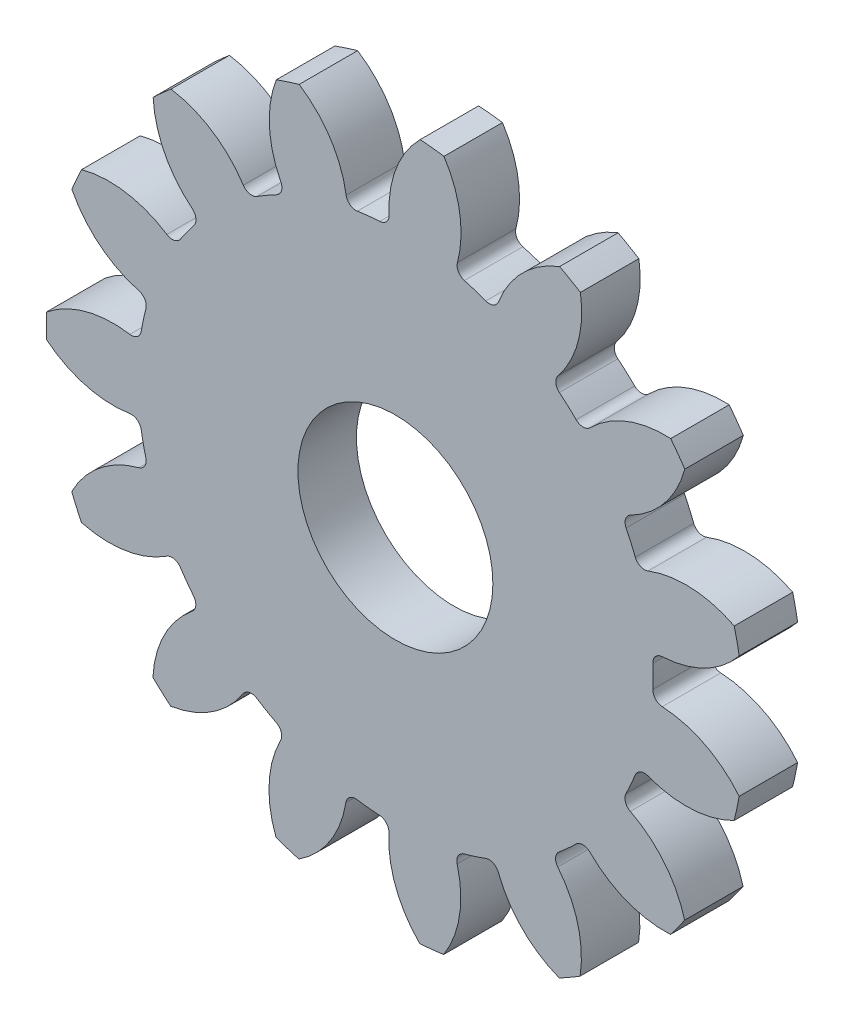
from build123d import *

# Parameters (mm, degrees)
CROQUIS1_R              = 17.907
SALIENTE_EXTRUIR1_DEPTH = 3
CORTAR_EXTRUIR1_DEPTH   = 4
REDONDEO1_R             = 0.508
MATRIZC1_COUNT          = 15
REDONDEO1_OF_MATRIZC1_R = 0.508
CROQUIS3_R              = 5
CORTAR_EXTRUIR2_DEPTH   = 4.0000001


with BuildPart() as part:
    # Croquis1 → Saliente-Extruir1 (new body)
    with BuildSketch(Plane.XY):
        Circle(CROQUIS1_R)
    extrude(amount=SALIENTE_EXTRUIR1_DEPTH)

    # Croquis2 → Cortar-Extruir1 (cut, through all)
    with BuildSketch(Plane.XY.offset(3)):
        with BuildLine():
            ThreePointArc((1.267657846, 17.86207414), (-1.862328, 17.80989566), (-4.935400263, 17.21343874))
            ThreePointArc((-4.935400263, 17.21343874), (-3.200886266, 15.393595888), (-2.472048776, 12.987527992))
            ThreePointArc((-2.472048776, 12.987527992), (-1.3749528, 13.149008072), (-0.268183485, 13.217979653))
            ThreePointArc((-0.268183485, 13.217979653), (-0.052860472, 15.722775615), (1.267657846, 17.86207414))
        make_face()
    cortar_extruir1 = extrude(amount=-CORTAR_EXTRUIR1_DEPTH, mode=Mode.SUBTRACT)

    # Redondeo1
    redondeo1_edges = [part.edges().sort_by_distance(p)[0] for p in [
        (-0.268183485, 13.217979653, 1.5),
        (-2.472048776, 12.987527992, 1.5),
    ]]
    fillet(redondeo1_edges, radius=REDONDEO1_R)

    # MatrizC1: Cortar-Extruir1 ×15 about axis
    matrizc1_axis = Axis((0, 0, 0), (0, 0, 1))
    for i in range(1, MATRIZC1_COUNT):
        add(cortar_extruir1.rotate(matrizc1_axis, i * 360 / MATRIZC1_COUNT), mode=Mode.SUBTRACT)

    # Redondeo1 of MatrizC1
    redondeo1_of_matrizc1_edges = [part.edges().sort_by_distance(p)[0] for p in [
        (-5.621234477, 11.966145221, 1.5),
        (-7.540832467, 10.859224382, 1.5),
        (-10.00232296, 8.645255571, 1.5),
        (-11.305737719, 6.853262224, 1.5),
        (-12.653918936, 3.829522694, 1.5),
        (-13.11577821, 1.662308768, 1.5),
        (-13.11753737, -1.648369448, 1.5),
        (-12.657981495, -3.816072977, 1.5),
        (-11.313014424, -6.841243537, 1.5),
        (-10.011504785, -8.634621035, 1.5),
        (-7.552368509, -10.851204468, 1.5),
        (-5.633947947, -11.960164674, 1.5),
        (-2.485849467, -12.984893566, 1.5),
        (-0.282230325, -13.217687185, 1.5),
        (3.010495531, -12.873376602, 1.5),
        (5.118287483, -12.189751504, 1.5),
        (7.986298502, -10.535935873, 1.5),
        (9.633806888, -9.054097047, 1.5),
        (11.581197909, -6.376736116, 1.5),
        (12.483553561, -4.352906957, 1.5),
        (13.173602985, -1.114940753, 1.5),
        (13.174780414, 1.100940291, 1.5),
        (12.488172427, 4.339637995, 1.5),
        (11.587968045, 6.364424961, 1.5),
        (9.643423405, 9.043853909, 1.5),
        (7.997490727, 10.527442736, 1.5),
        (5.131238868, 12.184305322, 1.5),
        (3.024174607, 12.870170024, 1.5),
    ]]
    fillet(redondeo1_of_matrizc1_edges, radius=REDONDEO1_OF_MATRIZC1_R)

    # Croquis3 → Cortar-Extruir2 (cut, through all)
    with BuildSketch(Plane.XY.offset(3)):
        Circle(CROQUIS3_R)
    extrude(amount=-CORTAR_EXTRUIR2_DEPTH, mode=Mode.SUBTRACT)


solid = part.part
